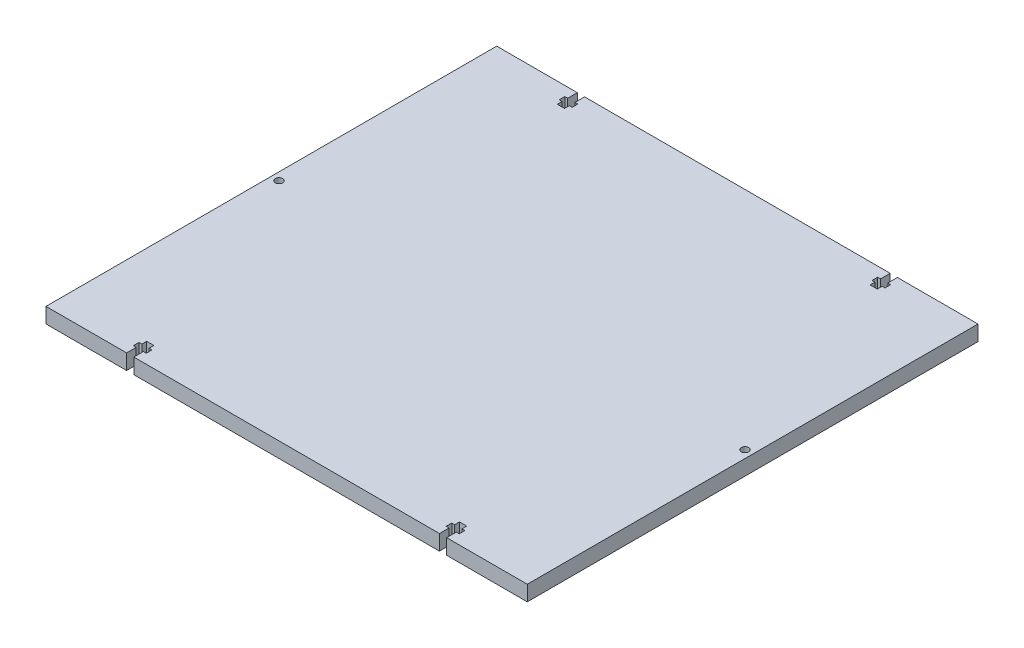
from build123d import *

# Parameters (mm, degrees)
SKETCH1_W           = 200
SKETCH1_H           = 187.3
BOSS_EXTRUDE1_DEPTH = 6.35
SKETCH2_R           = 1.55
CUT_EXTRUDE1_DEPTH  = 7.35


with BuildPart() as part:
    # Sketch1 → Boss-Extrude1 (new body)
    with BuildSketch(Plane(origin=(0, 0, 0), x_dir=(1, 0, 0), z_dir=(0, 1, 0))):
        Rectangle(SKETCH1_W, SKETCH1_H)
    extrude(amount=BOSS_EXTRUDE1_DEPTH)

    # Sketch2 → Cut-Extrude1 (cut, through all)
    with BuildSketch(Plane(origin=(0, 6.35, 0), x_dir=(1, 0, 0), z_dir=(0, 1, 0))):
        with Locations((-96.825, 0)):
            Circle(SKETCH2_R)
        with Locations((96.825, 0)):
            Circle(SKETCH2_R)
        Polygon((-63.5, 87.3), (-62.29, 87.3), (-62.29, 89.65), (-63.5, 89.65), (-63.5, 93.65), (-66.5, 93.65), (-66.5, 89.65), (-67.71, 89.65), (-67.71, 87.3), (-66.5, 87.3), (-66.5, 85.3), (-63.5, 85.3), align=None)
        Polygon((66.5, 93.65), (66.5, 89.65), (67.71, 89.65), (67.71, 87.3), (66.5, 87.3), (66.5, 85.3), (63.5, 85.3), (63.5, 87.3), (62.29, 87.3), (62.29, 89.65), (63.5, 89.65), (63.5, 93.65), align=None)
        Polygon((63.5, -87.3), (62.29, -87.3), (62.29, -89.65), (63.5, -89.65), (63.5, -93.65), (66.5, -93.65), (66.5, -89.65), (67.71, -89.65), (67.71, -87.3), (66.5, -87.3), (66.5, -85.3), (63.5, -85.3), align=None)
        Polygon((-66.5, -93.65), (-66.5, -89.65), (-67.71, -89.65), (-67.71, -87.3), (-66.5, -87.3), (-66.5, -85.3), (-63.5, -85.3), (-63.5, -87.3), (-62.29, -87.3), (-62.29, -89.65), (-63.5, -89.65), (-63.5, -93.65), align=None)
    extrude(amount=-CUT_EXTRUDE1_DEPTH, mode=Mode.SUBTRACT)


solid = part.part
